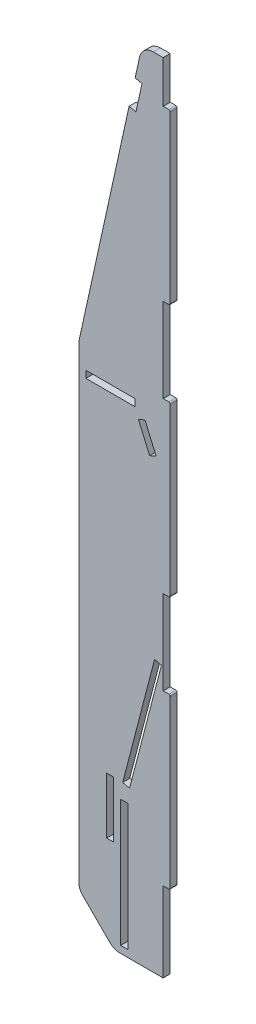
from build123d import *

# Parameters (mm, degrees)
BOSS_EXTRUDE1_DEPTH = 5
SKETCH2_W           = 5
SKETCH2_H           = 90
SKETCH2_H_2         = 40
SKETCH2_W_2         = 35
SKETCH2_H_3         = 5
CUT_EXTRUDE1_DEPTH  = 10
CUT_EXTRUDE2_DEPTH  = 10
FILLET1_R           = 1
FILLET2_R           = 10
CUT_EXTRUDE3_DEPTH  = 10


with BuildPart() as part:
    # Sketch1 → Boss-Extrude1 (new body)
    with BuildSketch(Plane.XY):
        Polygon((80, 33.22), (20, 33.22), (20, 600), (80, 600), (80, 570.05), (85, 570.05), (85, 449.95), (80, 449.95), (80, 390.05), (85, 390.05), (85, 269.95), (80, 269.95), (80, 210.05), (85, 210.05), (85, 89.95), (80, 89.95), align=None)
    extrude(amount=BOSS_EXTRUDE1_DEPTH)

    # Sketch2 → Cut-Extrude1 (cut)
    with BuildSketch(Plane.XY.offset(5)):
        Polygon((67, 370.417424305), (62.417424305, 368.417424305), (70.417424305, 350.087121525), (75, 352.087121525), align=None)
        Polygon((73.902811841, 226.418897298), (51.258042728, 139.314279557), (56.097188159, 138.056236829), (78.741957272, 225.16085457), align=None)
        with Locations((52.33914543, 83.217091399)):
            Rectangle(SKETCH2_W, SKETCH2_H)
        with Locations((42.33914543, 119.314279557)):
            Rectangle(SKETCH2_W, SKETCH2_H_2)
        with Locations((42.5, 377.5)):
            Rectangle(SKETCH2_W_2, SKETCH2_H_3)
    extrude(amount=-CUT_EXTRUDE1_DEPTH, mode=Mode.SUBTRACT)

    # Sketch3 → Cut-Extrude2 (cut)
    with BuildSketch(Plane.XY.offset(5)):
        Polygon((20, 395), (65, 600), (1.513631165, 616.08755832), align=None)
        Polygon((45, 33.22), (20, 58.22), (13.452472792, 20.556075169), align=None)
    extrude(amount=-CUT_EXTRUDE2_DEPTH, mode=Mode.SUBTRACT)

    # Fillet1
    fillet1_edges = [part.edges().sort_by_distance(p)[0] for p in [
        (85, 570.05, 2.5),
        (85, 449.95, 2.5),
        (85, 390.05, 2.5),
        (85, 269.95, 2.5),
        (85, 210.05, 2.5),
        (85, 89.95, 2.5),
    ]]
    fillet(fillet1_edges, radius=FILLET1_R)

    # Fillet2
    fillet2_edges = [part.edges().sort_by_distance(p)[0] for p in [
        (20, 395, 2.5),
        (65, 600, 2.5),
        (45, 33.22, 2.5),
        (20, 58.22, 2.5),
    ]]
    fillet(fillet2_edges, radius=FILLET2_R)

    # Sketch4 → Cut-Extrude3 (cut)
    with BuildSketch(Plane.XY.offset(5)):
        Polygon((60.059418786, 577.492907801), (64.943140501, 576.420871327), (60.654994605, 556.885984463), (55.771272889, 557.958020937), align=None)
    extrude(amount=-CUT_EXTRUDE3_DEPTH, mode=Mode.SUBTRACT)


solid = part.part
